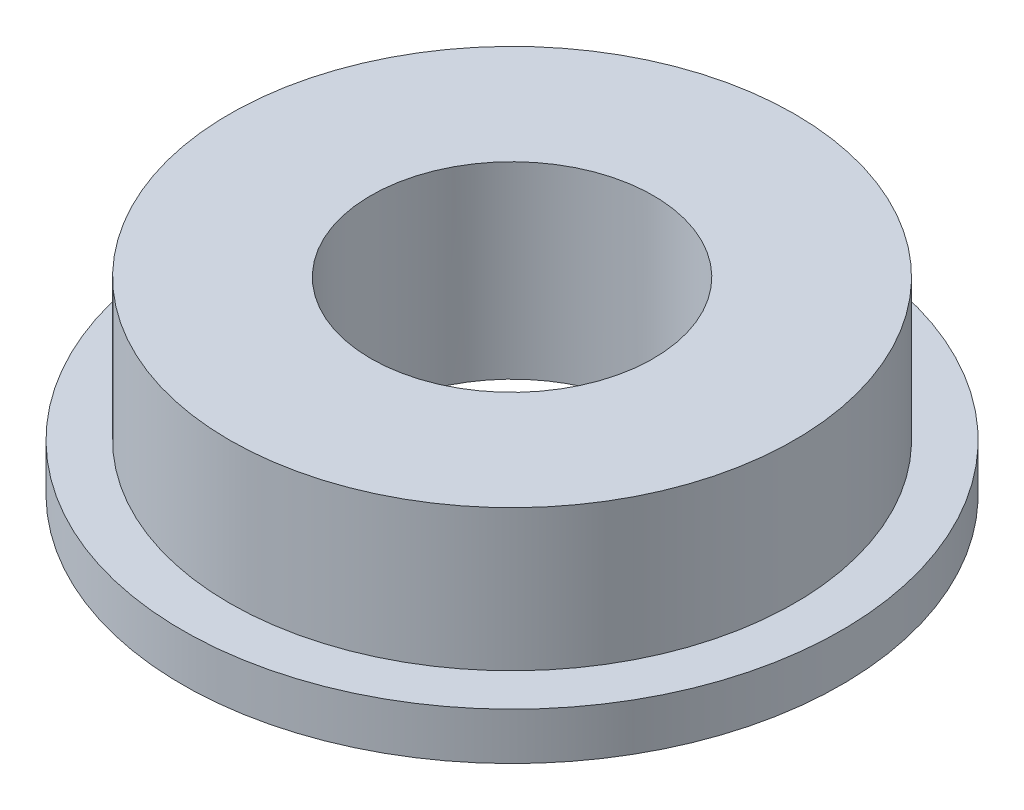
from build123d import *

# Parameters (mm, degrees)
SKETCH_2_R          = 3
CUT_EXTRUDE_1_DEPTH = 4


with BuildPart() as part:
    # 草图1 → 旋转1 (revolve)
    with BuildSketch(Plane.XY):
        Polygon((0, 0), (6, 0), (6, -3), (7, -3), (7, -4), (0, -4), align=None)
    revolve(axis=Axis((0, -4, 0), (0, 1, 0)))

    # 草图2 → 切除-拉伸1 (cut)
    with BuildSketch(Plane(origin=(0, 0, 0), x_dir=(1, 0, 0), z_dir=(0, 1, 0))):
        Circle(SKETCH_2_R)
    extrude(amount=-CUT_EXTRUDE_1_DEPTH, mode=Mode.SUBTRACT)


solid = part.part
